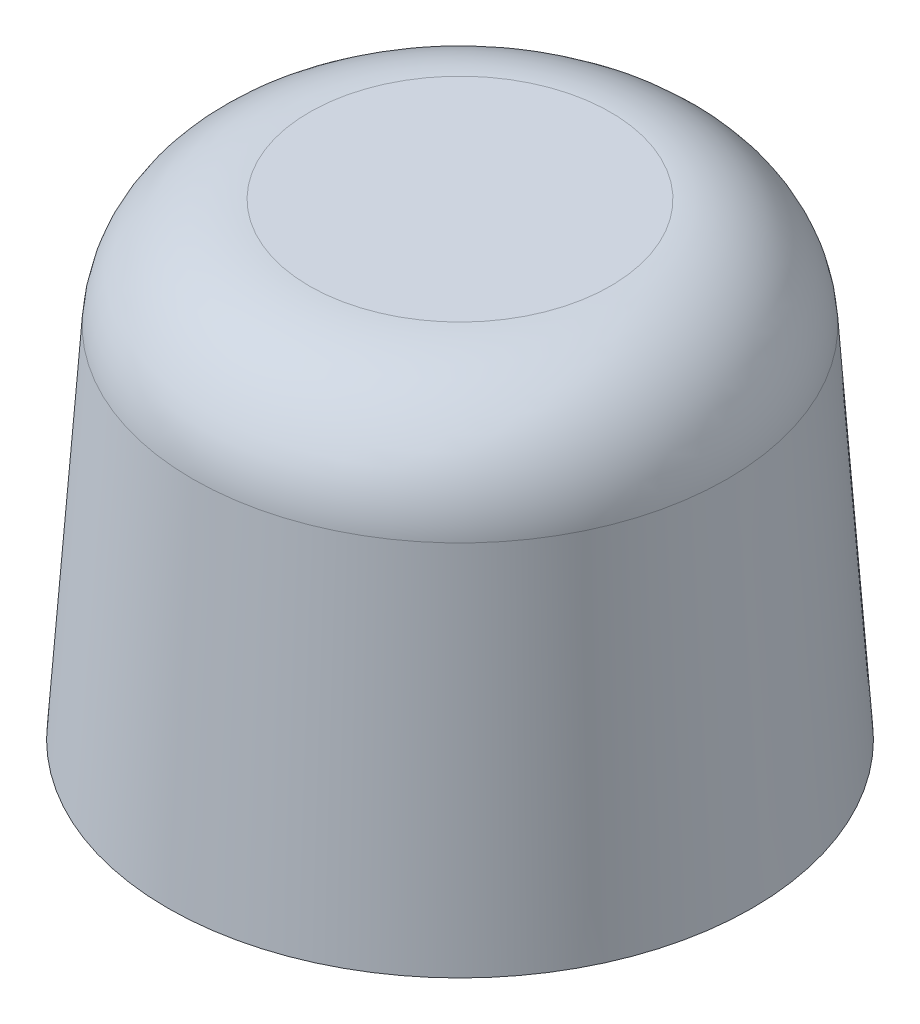
from build123d import *

# Parameters (mm, degrees)
SZKIC1_R                    = 50
DODANIE_WYCI_GNI_CIE1_DEPTH = 80
DODANIE_WYCI_GNI_CIE1_TAPER = 4
ZAOKR_GLENIE1_R             = 20


with BuildPart() as part:
    # Szkic1 → Dodanie-wyciągnięcie1 (new body)
    with BuildSketch(Plane(origin=(0, 0, 0), x_dir=(1, 0, 0), z_dir=(0, 1, 0))):
        Circle(SZKIC1_R)
    extrude(amount=DODANIE_WYCI_GNI_CIE1_DEPTH, taper=DODANIE_WYCI_GNI_CIE1_TAPER)

    # Zaokrąglenie1
    zaokr_glenie1_edges = [part.edges().sort_by_distance(p)[0] for p in [
        (-44.405855045, 80, 0),
    ]]
    fillet(zaokr_glenie1_edges, radius=ZAOKR_GLENIE1_R)


solid = part.part
